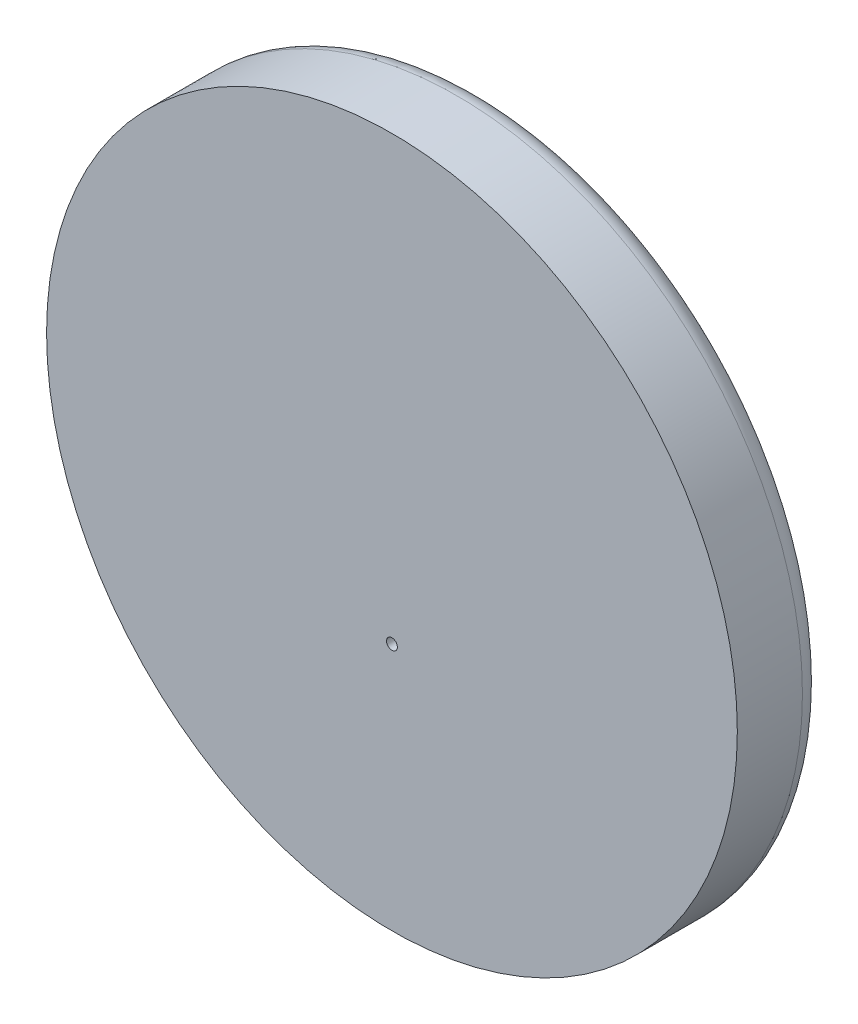
from build123d import *

# Parameters (mm, degrees)
SKETCH2_R           = 31.83
BOSS_EXTRUDE1_DEPTH = 8
FILLET1_R           = 2
SKETCH3_R           = 0.5
CUT_EXTRUDE1_DEPTH  = 9


with BuildPart() as part:
    # Sketch2 → Boss-Extrude1 (new body)
    with BuildSketch(Plane.XY):
        with Locations((0, 35.388213047)):
            Circle(SKETCH2_R)
    extrude(amount=BOSS_EXTRUDE1_DEPTH)

    # Fillet1
    fillet1_edges = [part.edges().sort_by_distance(p)[0] for p in [
        (-31.83, 35.388213047, 0),
    ]]
    fillet(fillet1_edges, radius=FILLET1_R)

    # Sketch3 → Cut-Extrude1 (cut, through all)
    with BuildSketch(Plane.XY.offset(8)):
        with Locations((0, 26.458213047)):
            Circle(SKETCH3_R)
    extrude(amount=-CUT_EXTRUDE1_DEPTH, mode=Mode.SUBTRACT)


solid = part.part
